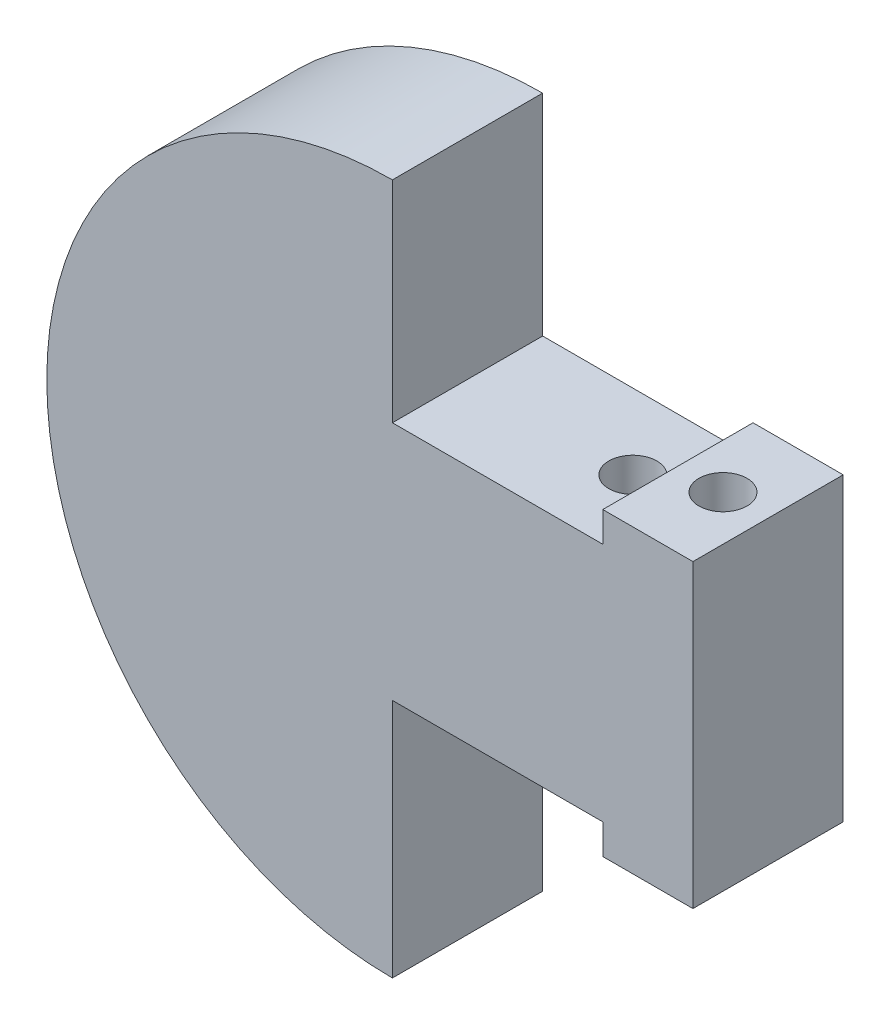
from build123d import *

# Parameters (mm, degrees)
BOSS_EXTRUDE1_DEPTH = 5
CUT_EXTRUDE1_START  = 11
SKETCH2_R           = 0.8
CUT_EXTRUDE1_DEPTH  = 23


with BuildPart() as part:
    # Sketch1 → Boss-Extrude1 (new body)
    with BuildSketch(Plane.XY):
        with BuildLine():
            Line((0, -11), (0, -3))
            Line((0, -3), (7, -3))
            Line((7, -3), (7, -4))
            Line((7, -4), (10, -4))
            Line((10, -4), (10, 6))
            Line((10, 6), (7, 6))
            Line((7, 6), (7, 5))
            Line((7, 5), (0, 5))
            Line((0, 5), (0, 12))
            ThreePointArc((0, 12), (-11.5, 0.5), (0, -11))
        make_face()
    extrude(amount=BOSS_EXTRUDE1_DEPTH)

    # Sketch2 → Cut-Extrude1 (cut, through all)
    with BuildSketch(Plane(origin=(0, 0, 0), x_dir=(1, 0, 0), z_dir=(0, 1, 0)).offset(CUT_EXTRUDE1_START)):
        with Locations((8.5, -2.5)):
            Circle(SKETCH2_R)
        with Locations((5.5, -2.5)):
            Circle(SKETCH2_R)
    extrude(amount=-CUT_EXTRUDE1_DEPTH, mode=Mode.SUBTRACT)


solid = part.part
